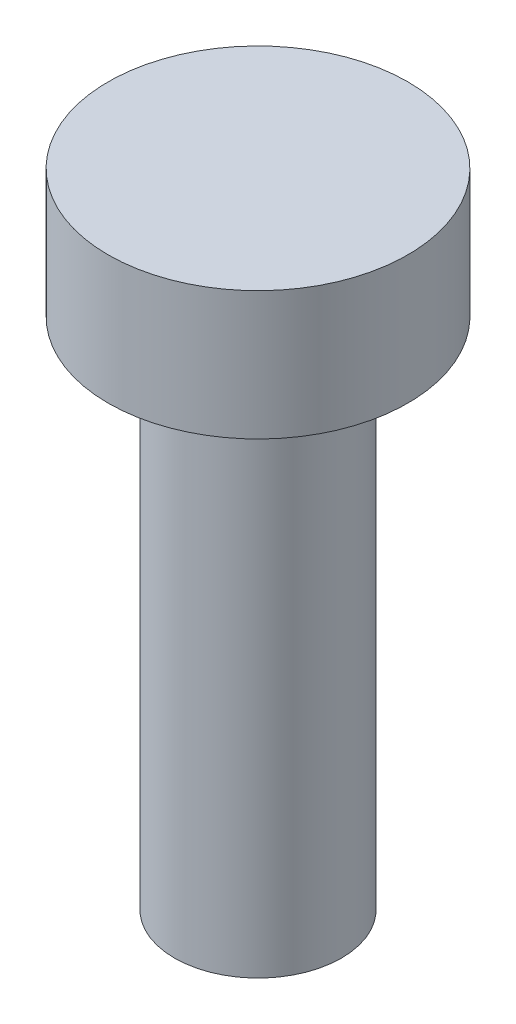
from build123d import *

# Parameters (mm, degrees)
SKETCH1_R           = 3.5
BOSS_EXTRUDE1_DEPTH = 3
SKETCH2_R           = 1.95
BOSS_EXTRUDE2_DEPTH = 12


with BuildPart() as part:
    # Sketch1 → Boss-Extrude1 (new body)
    with BuildSketch(Plane(origin=(0, 0, 0), x_dir=(1, 0, 0), z_dir=(0, 1, 0))):
        Circle(SKETCH1_R)
    extrude(amount=BOSS_EXTRUDE1_DEPTH)

    # Sketch2 → Boss-Extrude2 (add)
    with BuildSketch(Plane.XZ):
        Circle(SKETCH2_R)
    extrude(amount=BOSS_EXTRUDE2_DEPTH)


solid = part.part
